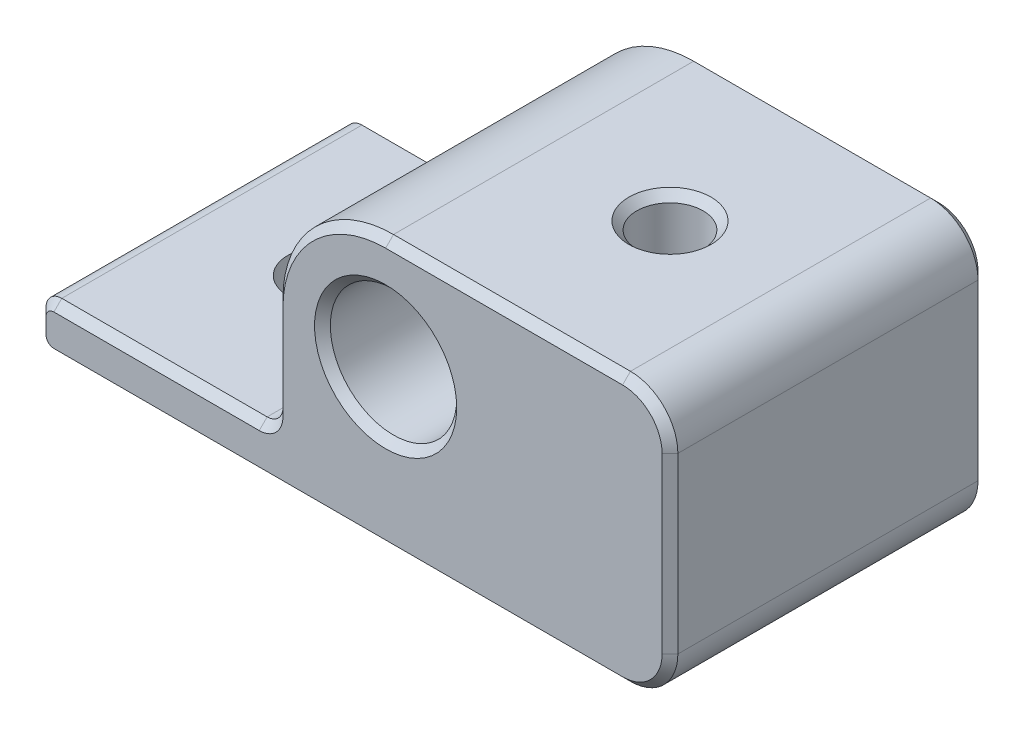
from build123d import *

# Parameters (mm, degrees)
SKETCH1_W                      = 40
SKETCH1_H                      = 20
BOSS_EXTRUDE1_DEPTH            = 17
SKETCH2_W                      = 15
SKETCH2_H                      = 14
CUT_EXTRUDE1_DEPTH             = 21
F_4_4_4_4_DIAMETER_HOLE1_D     = 4.4
F_4_4_4_4_DIAMETER_HOLE1_DEPTH = 17
F_4_2_4_2_DIAMETER_HOLE1_D     = 4.2
F_4_2_4_2_DIAMETER_HOLE1_DEPTH = 17
FILLET1_R                      = 1
FILLET2_R                      = 3
FILLET3_R                      = 7
CHAMFER1_SIZE                  = 0.5


with BuildPart() as part:
    # Sketch1 → Boss-Extrude1 (new body)
    with BuildSketch(Plane.XZ.offset(10)):
        with Locations((-2, 10)):
            Rectangle(SKETCH1_W, SKETCH1_H)
    extrude(amount=-BOSS_EXTRUDE1_DEPTH)

    # Sketch2 → Cut-Extrude1 (cut, through all)
    with BuildSketch(Plane.XY.offset(20)):
        with Locations((-14.5, 0)):
            Rectangle(SKETCH2_W, SKETCH2_H)
    extrude(amount=-CUT_EXTRUDE1_DEPTH, mode=Mode.SUBTRACT)

    # Ø4.4 (4.4) Diameter Hole1
    with Locations(Plane(origin=(0, -10, 0), x_dir=(-1, 0, 0), z_dir=(0, -1, 0))):
        with Locations((14, -10)):
            Hole(F_4_4_4_4_DIAMETER_HOLE1_D / 2, depth=F_4_4_4_4_DIAMETER_HOLE1_DEPTH)

    # Ø4.2 (4.2) Diameter Hole1
    with Locations(Plane(origin=(0, 7, 0), x_dir=(1, 0, 0), z_dir=(0, 1, 0))):
        with Locations((8, -10)):
            Hole(F_4_2_4_2_DIAMETER_HOLE1_D / 2, depth=F_4_2_4_2_DIAMETER_HOLE1_DEPTH)

    # Sketch7 → Hole1 (revolve, cut)
    with BuildSketch(Plane(origin=(0, 0, 20), x_dir=(0, -1, 0), z_dir=(1, 0, 0))):
        Polygon((0, 0), (0, 20), (3, 20), (3, 19), (4, 18), (4, 0), align=None)
    revolve(axis=Axis((0, 0, 26.130023899), (0, 0, -1)), mode=Mode.SUBTRACT)

    # Fillet1
    fillet1_edges = [part.edges().sort_by_distance(p)[0] for p in [
        (-7, -7, 10),
        (-22, -7, 10),
        (-22, -10, 10),
    ]]
    fillet(fillet1_edges, radius=FILLET1_R)

    # Fillet2
    fillet2_edges = [part.edges().sort_by_distance(p)[0] for p in [
        (18, 7, 10),
        (18, -10, 10),
    ]]
    fillet(fillet2_edges, radius=FILLET2_R)

    # Fillet3
    fillet3_edges = [part.edges().sort_by_distance(p)[0] for p in [
        (-7, 7, 10),
    ]]
    fillet(fillet3_edges, radius=FILLET3_R)

    # Chamfer1
    chamfer1_edges = [part.edges().sort_by_distance(p)[0] for p in [
        (10.1, 7, 10),
        (10.1, -10, 10),
        (0, 4, 20),
        (-7, -3, 20),
        (-7, -3, 0),
        (-14.5, -7, 20),
        (-14.5, -7, 0),
        (-22, -8.5, 20),
        (-21.707106781, -9.707106781, 20),
        (-21.707106781, -7.292893219, 20),
        (-22, -8.5, 0),
        (-3, -10, 0),
        (-21.707106781, -9.707106781, 0),
        (-21.707106781, -7.292893219, 0),
        (-7.292893219, -6.707106781, 20),
        (-7.292893219, -6.707106781, 0),
        (-3, -10, 20),
        (18, -1.5, 20),
        (7.5, 7, 20),
        (17.121320344, 6.121320344, 20),
        (17.121320344, -9.121320344, 20),
        (18, -1.5, 0),
        (17.121320344, 6.121320344, 0),
        (17.121320344, -9.121320344, 0),
        (7.5, 7, 0),
        (-4.949747468, 4.949747468, 20),
        (-4.949747468, 4.949747468, 0),
    ]]
    chamfer(chamfer1_edges, length=CHAMFER1_SIZE)


solid = part.part
